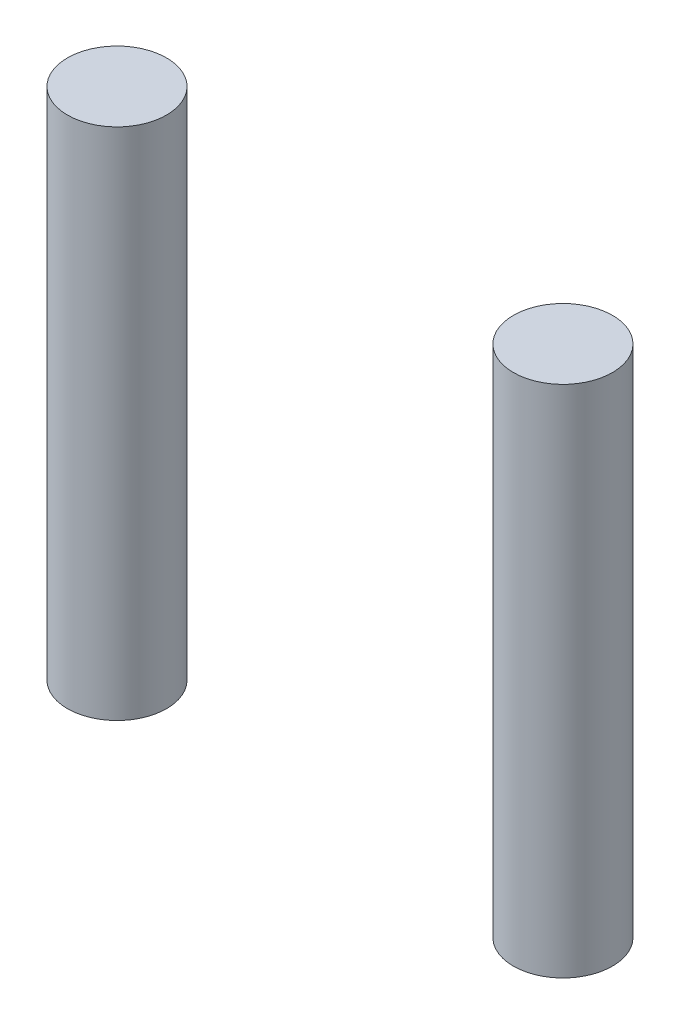
from build123d import *

# Parameters (mm, degrees)
SKETCH1_R             = 5
BOSS_EXTRUDE1_DEPTH   = 51.88
BOSS_EXTRUDE1_2_DEPTH = 51.88


with BuildPart() as part:
    # Sketch1 → Boss-Extrude1 (new body)
    with BuildSketch(Plane(origin=(0, 0, 0), x_dir=(1, 0, 0), z_dir=(0, 1, 0))):
        with Locations((-22.5, 0)):
            Circle(SKETCH1_R)
    extrude(amount=BOSS_EXTRUDE1_DEPTH)


with BuildPart() as body_2:
    # Sketch1 → Boss-Extrude1 2 (new body)
    with BuildSketch(Plane(origin=(0, 0, 0), x_dir=(1, 0, 0), z_dir=(0, 1, 0))):
        with Locations((22.5, 0)):
            Circle(SKETCH1_R)
    extrude(amount=BOSS_EXTRUDE1_2_DEPTH)


solid = Compound([part.part, body_2.part])
